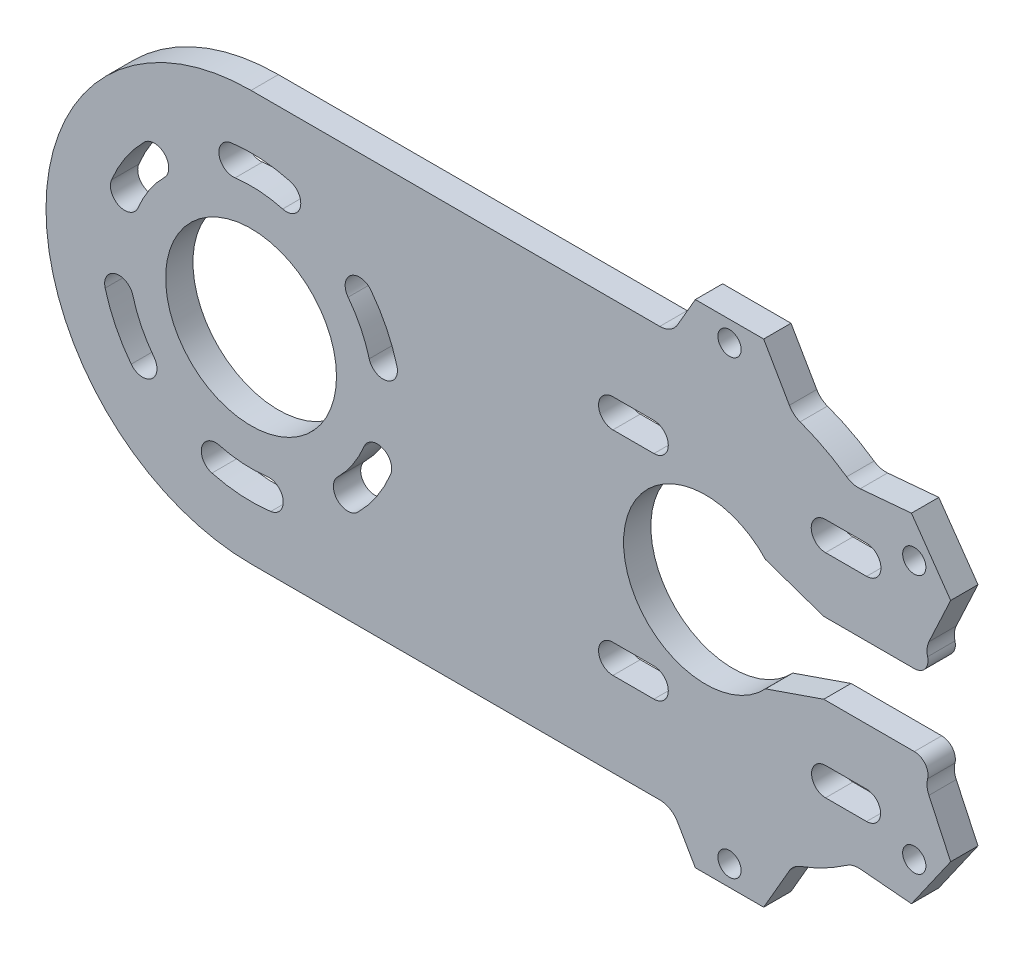
from build123d import *

# Parameters (mm, degrees)
SKIZZE1_R                       = 12.5
AUFSATZ_LINEAR_AUSTRAGEN1_DEPTH = 4
DURCHGANGSLOCH_F_R_M31_D        = 3.4
SCHNITT_LINEAR_AUSTRAGEN1_DEPTH = 5
SCHNITT_LINEAR_AUSTRAGEN2_DEPTH = 5


with BuildPart() as part:
    # Skizze1 → Aufsatz-Linear austragen1 (new body)
    with BuildSketch(Plane.XY):
        with BuildLine():
            Line((60.618791136, -25.122399911), (53.121982765, -24.466514166))
            ThreePointArc((53.121982765, -24.466514166), (52.087524265, -24.556394327), (51.145668645, -24.99353369))
            ThreePointArc((51.145668645, -24.99353369), (47.84965812, -26.988212977), (44.325198534, -28.544045699))
            ThreePointArc((44.325198534, -28.544045699), (43.426888741, -29.064835818), (42.759922204, -29.860661471))
            Line((42.759922204, -29.860661471), (38.997199723, -36.377887981))
            Line((38.997199723, -36.377887981), (28.997199723, -36.377887981))
            Line((28.997199723, -36.377887981), (26.399123512, -31.877887981))
            ThreePointArc((26.399123512, -31.877887981), (25.301047301, -30.77981177), (23.801047301, -30.377887981))
            Line((23.801047301, -30.377887981), (-36.002800277, -30.377887981))
            ThreePointArc((-36.002800277, -30.377887981), (-66.002800277, -0.377887981), (-36.002800277, 29.622112019))
            Line((-36.002800277, 29.622112019), (23.801047301, 29.622112019))
            ThreePointArc((23.801047301, 29.622112019), (25.301047301, 30.024035807), (26.399123512, 31.122112019))
            Line((26.399123512, 31.122112019), (28.997199723, 35.622112019))
            Line((28.997199723, 35.622112019), (38.997199723, 35.622112019))
            Line((38.997199723, 35.622112019), (42.759922204, 29.104885508))
            ThreePointArc((42.759922204, 29.104885508), (43.426888741, 28.309059855), (44.325198534, 27.788269736))
            ThreePointArc((44.325198534, 27.788269736), (47.84965812, 26.232437014), (51.145668645, 24.237757727))
            ThreePointArc((51.145668645, 24.237757727), (52.087524265, 23.800618365), (53.121982765, 23.710738204))
            Line((53.121982765, 23.710738204), (60.618791136, 24.366623949))
            Line((60.618791136, 24.366623949), (66.3545555, 16.175103506))
            Line((66.3545555, 16.175103506), (63.173776116, 9.353900106))
            ThreePointArc((63.173776116, 9.353900106), (62.906383033, 8.372251699), (62.982460357, 7.357685339))
            ThreePointArc((62.982460357, 7.357685339), (62.618871056, 5.641491574), (61.042300943, 4.872112019))
            Line((61.042300943, 4.872112019), (47.785287356, 4.872112019))
            Line((47.785287356, 4.872112019), (39.265024534, 7.815111963))
            ThreePointArc((39.265024534, 7.815111963), (18.497199723, -0.377887981), (39.265024534, -8.570887926))
            Line((39.265024534, -8.570887926), (47.785287356, -5.627887981))
            Line((47.785287356, -5.627887981), (61.042300943, -5.627887981))
            ThreePointArc((61.042300943, -5.627887981), (62.618871056, -6.397267536), (62.982460357, -8.113461302))
            ThreePointArc((62.982460357, -8.113461302), (62.906383033, -9.128027661), (63.173776116, -10.109676068))
            Line((63.173776116, -10.109676068), (66.3545555, -16.930879469))
            Line((66.3545555, -16.930879469), (60.618791136, -25.122399911))
        make_face()
        with Locations((-36.002800277, -0.377887981)):
            Circle(SKIZZE1_R, mode=Mode.SUBTRACT)
    extrude(amount=AUFSATZ_LINEAR_AUSTRAGEN1_DEPTH)

    # Durchgangsloch für M31 (through all)
    with Locations(Plane.XY.offset(4)):
        with Locations((33.997199723, 32.622112019), (61.029217185, 18.550134418), (61.029217185, -19.305910381), (33.997199723, -33.377887981)):
            Hole(DURCHGANGSLOCH_F_R_M31_D / 2)

    # Skizze6 → Schnitt-Linear austragen1 (cut, through all)
    with BuildSketch(Plane.XY.offset(4)):
        with BuildLine():
            ThreePointArc((-30.28289938, 20.96907278), (-34.557391121, 21.674794222), (-38.887429125, 21.533043455))
            ThreePointArc((-38.887429125, 21.533043455), (-40.69535833, 19.176904242), (-38.339219117, 17.368975037))
            ThreePointArc((-38.339219117, 17.368975037), (-34.832084263, 17.483786745), (-31.369939369, 16.912184309))
            ThreePointArc((-31.369939369, 16.912184309), (-28.797975139, 18.39710855), (-30.28289938, 20.96907278))
        make_face()
        with BuildLine():
            ThreePointArc((-14.655839516, 5.342012915), (-16.181912689, 9.396692073), (-18.469691456, 13.0757396))
            ThreePointArc((-18.469691456, 13.0757396), (-21.414132472, 13.463382613), (-21.801775485, 10.518941598))
            ThreePointArc((-21.801775485, 10.518941598), (-19.948778203, 7.539079574), (-18.712727986, 4.254972926))
            ThreePointArc((-18.712727986, 4.254972926), (-16.140763756, 2.770048686), (-14.655839516, 5.342012915))
        make_face()
        with BuildLine():
            ThreePointArc((-20.375740412, -16.004947846), (-17.627321845, -12.655990131), (-15.585062608, -8.835191837))
            ThreePointArc((-15.585062608, -8.835191837), (-16.721574418, -6.09140961), (-19.465356645, -7.227921421))
            ThreePointArc((-19.465356645, -7.227921421), (-21.119494216, -10.322595152), (-23.345588893, -13.035099365))
            ThreePointArc((-23.345588893, -13.035099365), (-23.345588893, -16.004947846), (-20.375740412, -16.004947846))
        make_face()
        with BuildLine():
            ThreePointArc((-41.722701173, -21.724848742), (-37.448209433, -22.430570185), (-33.118171429, -22.288819418))
            ThreePointArc((-33.118171429, -22.288819418), (-31.310242223, -19.932680205), (-33.666381436, -18.124751))
            ThreePointArc((-33.666381436, -18.124751), (-37.17351629, -18.239562707), (-40.635661184, -17.667960272))
            ThreePointArc((-40.635661184, -17.667960272), (-43.207625414, -19.152884512), (-41.722701173, -21.724848742))
        make_face()
        with BuildLine():
            ThreePointArc((-57.349761038, -6.097788878), (-55.823687864, -10.152468035), (-53.535909097, -13.831515562))
            ThreePointArc((-53.535909097, -13.831515562), (-50.591468081, -14.219158576), (-50.203825068, -11.274717561))
            ThreePointArc((-50.203825068, -11.274717561), (-52.05682235, -8.294855536), (-53.292872567, -5.010748889))
            ThreePointArc((-53.292872567, -5.010748889), (-55.864836797, -3.525824648), (-57.349761038, -6.097788878))
        make_face()
        with BuildLine():
            ThreePointArc((-51.629860141, 15.249171883), (-54.378278708, 11.900214168), (-56.420537945, 8.079415874))
            ThreePointArc((-56.420537945, 8.079415874), (-55.284026135, 5.335633648), (-52.540243909, 6.472145458))
            ThreePointArc((-52.540243909, 6.472145458), (-50.886106337, 9.56681919), (-48.66001166, 12.279323402))
            ThreePointArc((-48.66001166, 12.279323402), (-48.66001166, 15.249171883), (-51.629860141, 15.249171883))
        make_face()
    extrude(amount=-SCHNITT_LINEAR_AUSTRAGEN1_DEPTH, mode=Mode.SUBTRACT)

    # Skizze7 → Schnitt-Linear austragen2 (cut, through all)
    with BuildSketch(Plane.XY.offset(4)):
        with BuildLine():
            Line((16.940850537, 17.278461205), (22.940850537, 17.278461205))
            ThreePointArc((22.940850537, 17.278461205), (25.040850537, 15.178461205), (22.940850537, 13.078461205))
            Line((22.940850537, 13.078461205), (16.940850537, 13.078461205))
            ThreePointArc((16.940850537, 13.078461205), (14.840850537, 15.178461205), (16.940850537, 17.278461205))
        make_face()
        with BuildLine():
            Line((48.05354891, 17.278461205), (54.05354891, 17.278461205))
            ThreePointArc((54.05354891, 17.278461205), (56.15354891, 15.178461205), (54.05354891, 13.078461205))
            Line((54.05354891, 13.078461205), (48.05354891, 13.078461205))
            ThreePointArc((48.05354891, 13.078461205), (45.95354891, 15.178461205), (48.05354891, 17.278461205))
        make_face()
        with BuildLine():
            Line((54.05354891, -17.984237167), (48.05354891, -17.984237167))
            ThreePointArc((48.05354891, -17.984237167), (46.00354891, -15.934237167), (48.05354891, -13.884237167))
            Line((48.05354891, -13.884237167), (54.05354891, -13.884237167))
            ThreePointArc((54.05354891, -13.884237167), (56.10354891, -15.934237167), (54.05354891, -17.984237167))
        make_face()
        with BuildLine():
            Line((22.940850537, -18.034237167), (16.940850537, -18.034237167))
            ThreePointArc((16.940850537, -18.034237167), (14.840850537, -15.934237167), (16.940850537, -13.834237167))
            Line((16.940850537, -13.834237167), (22.940850537, -13.834237167))
            ThreePointArc((22.940850537, -13.834237167), (25.040850537, -15.934237167), (22.940850537, -18.034237167))
        make_face()
    extrude(amount=-SCHNITT_LINEAR_AUSTRAGEN2_DEPTH, mode=Mode.SUBTRACT)


solid = part.part
